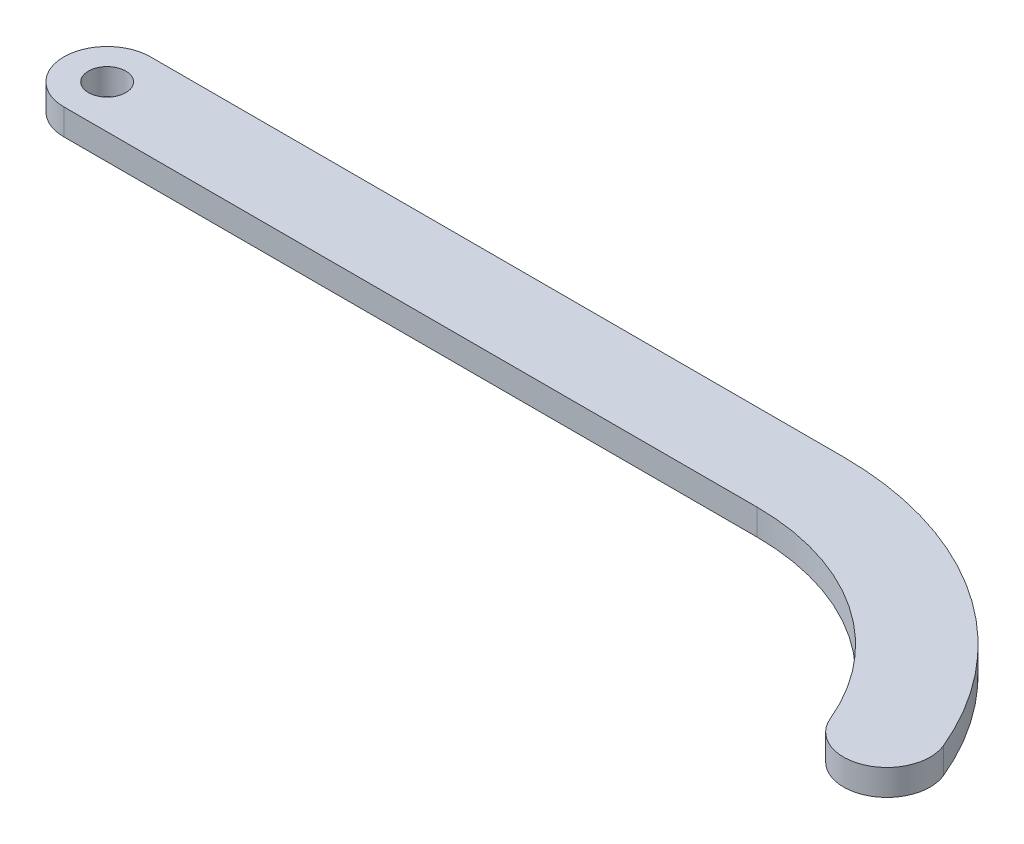
from build123d import *

# Parameters (mm, degrees)
BOSS_EXTRUDE1_DEPTH = 3
CUT_EXTRUDE1_REACH  = 5
SKETCH2_R           = 2.159


with BuildPart() as part:
    # Sketch1 → Boss-Extrude1 (new body)
    with BuildSketch(Plane(origin=(0, 0, 0), x_dir=(1, 0, 0), z_dir=(0, 1, 0))):
        with BuildLine():
            Line((0, 5), (80, 5))
            ThreePointArc((80, 5), (100.801257358, -1.298113962), (114.615384615, -18.076923077))
            ThreePointArc((114.615384615, -18.076923077), (111.923076923, -24.615384615), (105.384615385, -21.923076923))
            ThreePointArc((105.384615385, -21.923076923), (95.254255396, -9.618616906), (80, -5))
            Line((80, -5), (0, -5))
            ThreePointArc((0, -5), (-5, 0), (0, 5))
        make_face()
    extrude(amount=BOSS_EXTRUDE1_DEPTH)

    # Sketch2 → Cut-Extrude1 (cut, up to next)
    with BuildSketch(Plane(origin=(0, 3, 0), x_dir=(1, 0, 0), z_dir=(0, 1, 0)), mode=Mode.PRIVATE) as cut_extrude1_sk1:
        Circle(SKETCH2_R)
    cut_extrude1_tool1 = extrude(cut_extrude1_sk1.sketch, amount=-CUT_EXTRUDE1_REACH, mode=Mode.PRIVATE) & part.part
    add(cut_extrude1_tool1.solids().sort_by_distance((0, 3, 0))[0], mode=Mode.SUBTRACT)


solid = part.part
